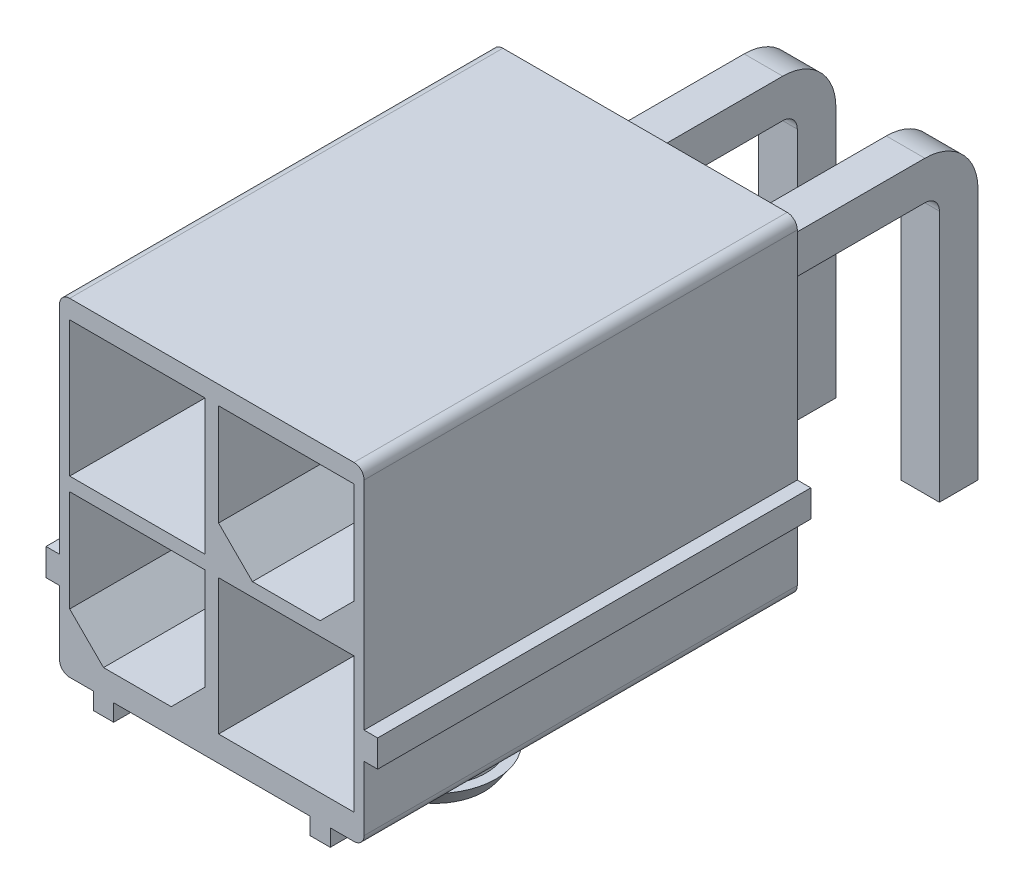
from build123d import *

# Parameters (mm, degrees)
BOSS_EXTRUDE1_DEPTH = 12.8
SKETCH2_W           = 1.14
SKETCH2_H           = 1.14
SKETCH4_W           = 1.14
SKETCH4_H           = 1.14
LPATTERN2_COUNT     = 2
LPATTERN2_PITCH     = 4.2
LPATTERN3_COUNT     = 2
LPATTERN3_PITCH     = 4.2
FILLET1_R           = 0.3
SKETCH6_W           = 4
SKETCH6_H           = 4
CUT_EXTRUDE1_DEPTH  = 12
SKETCH9_W           = 1.6
SKETCH9_H           = 3.5
CUT_EXTRUDE2_DEPTH  = 20.97


with BuildPart() as part:
    # Sketch1 → Boss-Extrude1 (new body)
    with BuildSketch(Plane.XY):
        Polygon((-4.5, 0.5), (-3.5, 0.5), (-3.5, 0), (-2.9, 0), (-2.9, 0.5), (2.9, 0.5), (2.9, 0), (3.5, 0), (3.5, 0.5), (4.5, 0.5), (4.5, 2.7), (4.9, 2.7), (4.9, 3.5), (4.5, 3.5), (4.5, 10.2), (-4.5, 10.2), (-4.5, 3.5), (-4.9, 3.5), (-4.9, 2.7), (-4.5, 2.7), align=None)
    extrude(amount=-BOSS_EXTRUDE1_DEPTH)

    # Sweep2: sweep along a path in Sketch3
    with BuildLine(Plane(origin=(2.1, 0, 0), x_dir=(0, 0, -1), z_dir=(1, 0, 0))) as sweep2_path:
        Line((12.8, 7.45), (18.4, 7.45))
        ThreePointArc((18.4, 7.45), (19.107106781, 7.157106781), (19.4, 6.45))
        Line((19.4, 6.45), (19.4, -1))
    # Sketch2 → Sweep2 (sweep)
    with BuildSketch(Plane(origin=(0, 0, -12.8), x_dir=(-1, 0, 0), z_dir=(0, 0, -1))):
        with Locations((-2.1, 7.45)):
            Rectangle(SKETCH2_W, SKETCH2_H)
    sweep2 = sweep(path=sweep2_path.line)

    # Sweep3: sweep along a path in Sketch5
    with BuildLine(Plane(origin=(2.1, 0, 0), x_dir=(0, 0, -1), z_dir=(1, 0, 0))) as sweep3_path:
        Line((12.8, 3.25), (12.9, 3.25))
        ThreePointArc((12.9, 3.25), (13.607106781, 2.957106781), (13.9, 2.25))
        Line((13.9, 2.25), (13.9, -1))
    # Sketch4 → Sweep3 (sweep)
    with BuildSketch(Plane(origin=(0, 0, -12.8), x_dir=(-1, 0, 0), z_dir=(0, 0, -1))):
        with Locations((-2.1, 3.25)):
            Rectangle(SKETCH4_W, SKETCH4_H)
    sweep3 = sweep(path=sweep3_path.line)

    # LPattern2: Sweep2 ×2
    with Locations(*[(-i * LPATTERN2_PITCH, 0, 0) for i in range(1, LPATTERN2_COUNT)]):
        add(sweep2)

    # LPattern3: Sweep3 ×2
    with Locations(*[(-i * LPATTERN3_PITCH, 0, 0) for i in range(1, LPATTERN3_COUNT)]):
        add(sweep3)

    # Fillet1
    fillet1_edges = [part.edges().sort_by_distance(p)[0] for p in [
        (-4.5, 10.2, -6.4),
        (4.5, 10.2, -6.4),
        (4.5, 0.5, -6.4),
        (-4.5, 0.5, -6.4),
    ]]
    fillet(fillet1_edges, radius=FILLET1_R)

    # Sketch6 → Cut-Extrude1 (cut)
    with BuildSketch(Plane.XY):
        Polygon((-4.2, 2.25), (-3.2, 1.25), (-1.2, 1.25), (-0.2, 2.25), (-0.2, 5.25), (-4.2, 5.25), align=None)
        with Locations((-2.2, 7.65)):
            Rectangle(SKETCH6_W, SKETCH6_H)
        with Locations((2.2, 3.25)):
            Rectangle(SKETCH6_W, SKETCH6_H)
        Polygon((0.2, 9.65), (4.2, 9.65), (4.2, 6.65), (3.2, 5.65), (1.2, 5.65), (0.2, 6.65), align=None)
    extrude(amount=-CUT_EXTRUDE1_DEPTH, mode=Mode.SUBTRACT)

    # Sketch8 → Revolve1 (revolve)
    with BuildSketch(Plane(origin=(0, 0, 0), x_dir=(0, 0, -1), z_dir=(1, 0, 0))):
        Polygon((5.6, 0.5), (5.6, -2.9), (5.150103769, -2.9), (4.8, -2.4), (5.1, -2.4), (5.1, 0.5), align=None)
    revolve(axis=Axis((0, 0.5, -6.6), (0, -1, 0)))

    # Sketch9 → Cut-Extrude2 (cut, through all)
    with BuildSketch(Plane.XY):
        with Locations((0, -1.25)):
            Rectangle(SKETCH9_W, SKETCH9_H)
    extrude(amount=-CUT_EXTRUDE2_DEPTH, mode=Mode.SUBTRACT)


solid = part.part
